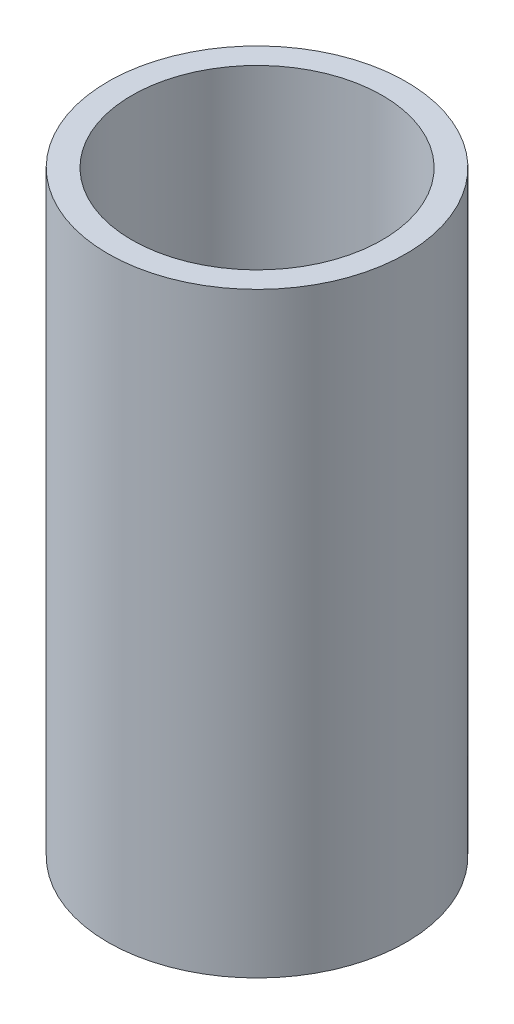
from build123d import *

# Parameters (mm, degrees)
SKETCH1_R           = 2.5
SKETCH1_R_2         = 2.1
BOSS_EXTRUDE1_DEPTH = 10


with BuildPart() as part:
    # Sketch1 → Boss-Extrude1 (new body)
    with BuildSketch(Plane(origin=(0, 0, 0), x_dir=(1, 0, 0), z_dir=(0, 1, 0))):
        Circle(SKETCH1_R)
        Circle(SKETCH1_R_2, mode=Mode.SUBTRACT)
    extrude(amount=BOSS_EXTRUDE1_DEPTH)


solid = part.part
